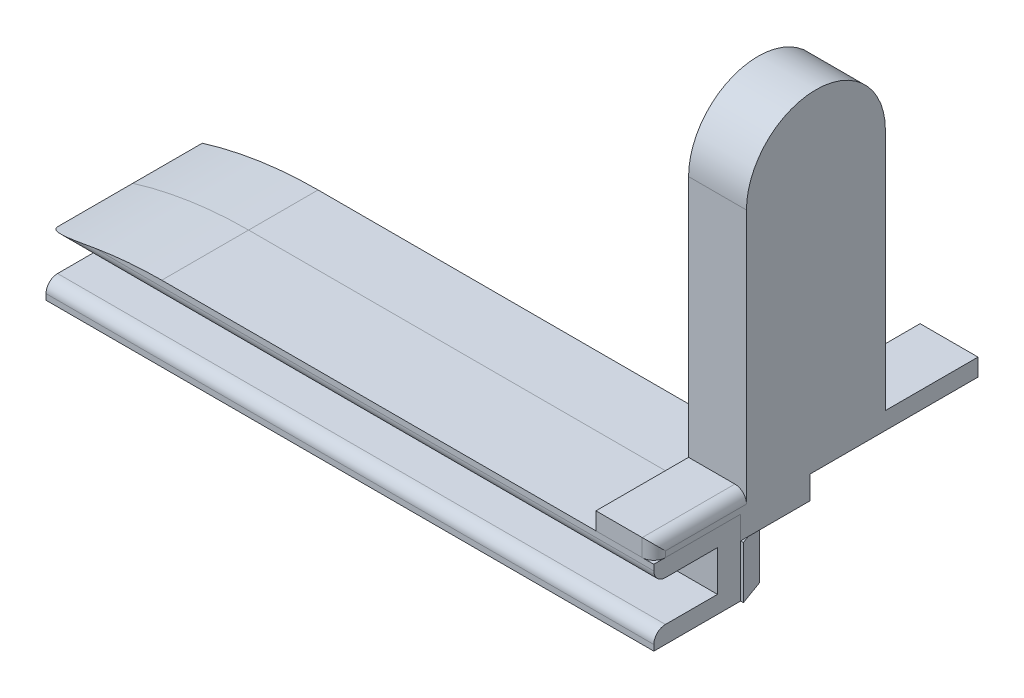
from build123d import *

# Parameters (mm, degrees)
SKETCH1_W           = 65
SKETCH1_H           = 2
BOSS_EXTRUDE1_DEPTH = 6.5
BOSS_EXTRUDE2_DEPTH = 4.5
SKETCH5_W           = 67
SKETCH5_H           = 1.5
BOSS_EXTRUDE6_DEPTH = 5.5
BOSS_EXTRUDE7_DEPTH = 5
SKETCH7_W           = 65
SKETCH7_H           = 2
BOSS_EXTRUDE8_DEPTH = 6
SKETCH8_W           = 25.322951889
SKETCH8_H           = 29.09091251
CUT_EXTRUDE1_DEPTH  = 36
CUT_EXTRUDE2_DEPTH  = 29
FILLET5_R           = 1
FILLET7_R           = 1


with BuildPart() as part:
    # Sketch1 → Boss-Extrude1 (new body)
    with BuildSketch(Plane(origin=(0, 0, 0), x_dir=(1, 0, 0), z_dir=(0, 1, 0))):
        with Locations((-31.358656154, 5.24806396)):
            Rectangle(SKETCH1_W, SKETCH1_H)
    extrude(amount=BOSS_EXTRUDE1_DEPTH)

    # Sketch2 → Boss-Extrude2 (add)
    with BuildSketch(Plane(origin=(0, 0, 0), x_dir=(1, 0, 0), z_dir=(0, 1, 0))):
        Polygon((-63.058656154, 8.44806396), (-63.858656154, 6.24806396), (-61.418656154, 6.24806396), (-62.218656154, 8.44806396), align=None)
        Polygon((-59.918656154, 8.44806396), (-60.718656154, 6.24806396), (-58.278656154, 6.24806396), (-59.078656154, 8.44806396), align=None)
        Polygon((-56.778656154, 8.44806396), (-57.578656154, 6.24806396), (-55.138656154, 6.24806396), (-55.938656154, 8.44806396), align=None)
        Polygon((-53.638656154, 8.44806396), (-54.438656154, 6.24806396), (-51.998656154, 6.24806396), (-52.798656154, 8.44806396), align=None)
        Polygon((-50.498656154, 8.44806396), (-51.298656154, 6.24806396), (-48.858656154, 6.24806396), (-49.658656154, 8.44806396), align=None)
        Polygon((-47.358656154, 8.44806396), (-48.158656154, 6.24806396), (-45.718656154, 6.24806396), (-46.518656154, 8.44806396), align=None)
        Polygon((-44.218656154, 8.44806396), (-45.018656154, 6.24806396), (-42.578656154, 6.24806396), (-43.378656154, 8.44806396), align=None)
        Polygon((-41.078656154, 8.44806396), (-41.878656154, 6.24806396), (-39.438656154, 6.24806396), (-40.238656154, 8.44806396), align=None)
        Polygon((-37.938656154, 8.44806396), (-38.738656154, 6.24806396), (-36.298656154, 6.24806396), (-37.098656154, 8.44806396), align=None)
        Polygon((-34.798656154, 8.44806396), (-35.598656154, 6.24806396), (-33.158656154, 6.24806396), (-33.958656154, 8.44806396), align=None)
        Polygon((-31.658656154, 8.44806396), (-32.458656154, 6.24806396), (-30.018656154, 6.24806396), (-30.818656154, 8.44806396), align=None)
        Polygon((-29.318656154, 6.24806396), (-26.878656154, 6.24806396), (-27.678656154, 8.44806396), (-28.518656154, 8.44806396), align=None)
        Polygon((-26.178656154, 6.24806396), (-23.738656154, 6.24806396), (-24.538656154, 8.44806396), (-25.378656154, 8.44806396), align=None)
        Polygon((-23.038656154, 6.24806396), (-20.598656154, 6.24806396), (-21.398656154, 8.44806396), (-22.238656154, 8.44806396), align=None)
        Polygon((-19.898656154, 6.24806396), (-17.458656154, 6.24806396), (-18.258656154, 8.44806396), (-19.098656154, 8.44806396), align=None)
        Polygon((-16.758656154, 6.24806396), (-14.318656154, 6.24806396), (-15.118656154, 8.44806396), (-15.958656154, 8.44806396), align=None)
        Polygon((-13.618656154, 6.24806396), (-11.178656154, 6.24806396), (-11.978656154, 8.44806396), (-12.818656154, 8.44806396), align=None)
        Polygon((-10.478656154, 6.24806396), (-8.038656154, 6.24806396), (-8.838656154, 8.44806396), (-9.678656154, 8.44806396), align=None)
        Polygon((-7.338656154, 6.24806396), (-4.898656154, 6.24806396), (-5.698656154, 8.44806396), (-6.538656154, 8.44806396), align=None)
        Polygon((-4.198656154, 6.24806396), (-1.758656154, 6.24806396), (-2.558656154, 8.44806396), (-3.398656154, 8.44806396), align=None)
        Polygon((-3.398656154, 8.44806396), (-4.198656154, 6.24806396), (-1.758656154, 6.24806396), (-2.558656154, 8.44806396), align=None)
        Polygon((-0.258656154, 8.44806396), (-1.058656154, 6.24806396), (1.141343846, 6.24806396), (1.381343846, 6.24806396), (0.581343846, 8.44806396), align=None)
        Polygon((-6.538656154, 8.44806396), (-7.338656154, 6.24806396), (-4.898656154, 6.24806396), (-5.698656154, 8.44806396), align=None)
        Polygon((-9.678656154, 8.44806396), (-10.478656154, 6.24806396), (-8.038656154, 6.24806396), (-8.838656154, 8.44806396), align=None)
        Polygon((-12.818656154, 8.44806396), (-13.618656154, 6.24806396), (-11.178656154, 6.24806396), (-11.978656154, 8.44806396), align=None)
        Polygon((-15.958656154, 8.44806396), (-16.758656154, 6.24806396), (-14.318656154, 6.24806396), (-15.118656154, 8.44806396), align=None)
        Polygon((-19.098656154, 8.44806396), (-19.898656154, 6.24806396), (-17.458656154, 6.24806396), (-18.258656154, 8.44806396), align=None)
        Polygon((-22.238656154, 8.44806396), (-23.038656154, 6.24806396), (-20.598656154, 6.24806396), (-21.398656154, 8.44806396), align=None)
        Polygon((-25.378656154, 8.44806396), (-26.178656154, 6.24806396), (-23.738656154, 6.24806396), (-24.538656154, 8.44806396), align=None)
        Polygon((-28.518656154, 8.44806396), (-29.318656154, 6.24806396), (-26.878656154, 6.24806396), (-27.678656154, 8.44806396), align=None)
    extrude(amount=BOSS_EXTRUDE2_DEPTH)

    # Sketch5 → Boss-Extrude6 (add)
    with BuildSketch(Plane.XY.offset(-4.24806396)):
        with Locations((-32.358656154, 0.75)):
            Rectangle(SKETCH5_W, SKETCH5_H)
        with Locations((-32.358656154, 5.75)):
            Rectangle(SKETCH5_W, SKETCH5_H)
    extrude(amount=BOSS_EXTRUDE6_DEPTH)


with BuildPart() as body_2:
    # Sketch6 → Boss-Extrude7 (new body)
    with BuildSketch(Plane(origin=(1.141343846, 0, 0), x_dir=(0, 0, -1), z_dir=(1, 0, 0))):
        with BuildLine():
            Line((-1.25193604, 6.5), (6.24806396, 6.5))
            Line((6.24806396, 6.5), (26.74806396, 6.5))
            Line((26.74806396, 6.5), (26.74806396, 8))
            Line((26.74806396, 8), (18.74806396, 8))
            Line((18.74806396, 8), (18.74806396, 29))
            ThreePointArc((18.74806396, 29), (12.74806396, 35), (6.74806396, 29))
            Line((6.74806396, 29), (6.74806396, 8))
            Line((6.74806396, 8), (-1.25193604, 8))
            Line((-1.25193604, 8), (-1.25193604, 6.5))
        make_face()
    extrude(amount=-BOSS_EXTRUDE7_DEPTH)

    # Sketch7 → Boss-Extrude8 (add)
    with BuildSketch(Plane(origin=(0, 0, -6.24806396), x_dir=(-1, 0, 0), z_dir=(0, 0, -1))):
        with Locations((31.358656154, 5.5)):
            Rectangle(SKETCH7_W, SKETCH7_H)
    extrude(amount=BOSS_EXTRUDE8_DEPTH)


with BuildPart() as cut_extrude1_tool:
    # Sketch8 → Cut-Extrude1 (new body, through all)
    with BuildSketch(Plane(origin=(0, 0, 0), x_dir=(-1, 0, 0), z_dir=(0, -1, 0))):
        with Locations((64.020245629, 5.403519831)):
            Rectangle(SKETCH8_W, SKETCH8_H)
    extrude(amount=-CUT_EXTRUDE1_DEPTH)


with BuildPart() as part_1:
    add(part.part)

    # Cut-Extrude1: cut by cut_extrude1_tool
    add(cut_extrude1_tool.part, mode=Mode.SUBTRACT)


with BuildPart() as body_2_1:
    add(body_2.part)

    # Cut-Extrude1: cut by cut_extrude1_tool
    add(cut_extrude1_tool.part, mode=Mode.SUBTRACT)


with BuildPart() as cut_extrude2_tool:
    # Sketch10 → Cut-Extrude2 (new body, through all)
    with BuildSketch(Plane.XY.offset(1.25193604)):
        with BuildLine():
            Line((-51.358769684, 6.5), (-51.358769684, 5))
            ThreePointArc((-51.358769684, 5), (-46.414706788, 6.122914027), (-41.358769684, 6.5))
            Line((-41.358769684, 6.5), (-51.358769684, 6.5))
        make_face()
    extrude(amount=-CUT_EXTRUDE2_DEPTH)


with BuildPart() as part_2:
    add(part_1.part)

    # Cut-Extrude2: cut by cut_extrude2_tool
    add(cut_extrude2_tool.part, mode=Mode.SUBTRACT)

    # Fillet7
    fillet7_edges = [part_2.edges().sort_by_distance(p)[0] for p in [
        (-25.108712919, 5, 1.25193604),
        (-25.108712919, 1.5, 1.25193604),
    ]]
    fillet(fillet7_edges, radius=FILLET7_R)


with BuildPart() as body_2_2:
    add(body_2_1.part)

    # Cut-Extrude2: cut by cut_extrude2_tool
    add(cut_extrude2_tool.part, mode=Mode.SUBTRACT)

    # Fillet5
    fillet5_edges = [body_2_2.edges().sort_by_distance(p)[0] for p in [
        (1.141343846, 7.25, 1.25193604),
        (1.141343846, 8, -2.74806396),
    ]]
    fillet(fillet5_edges, radius=FILLET5_R)


solid = Compound([part_2.part, body_2_2.part])
